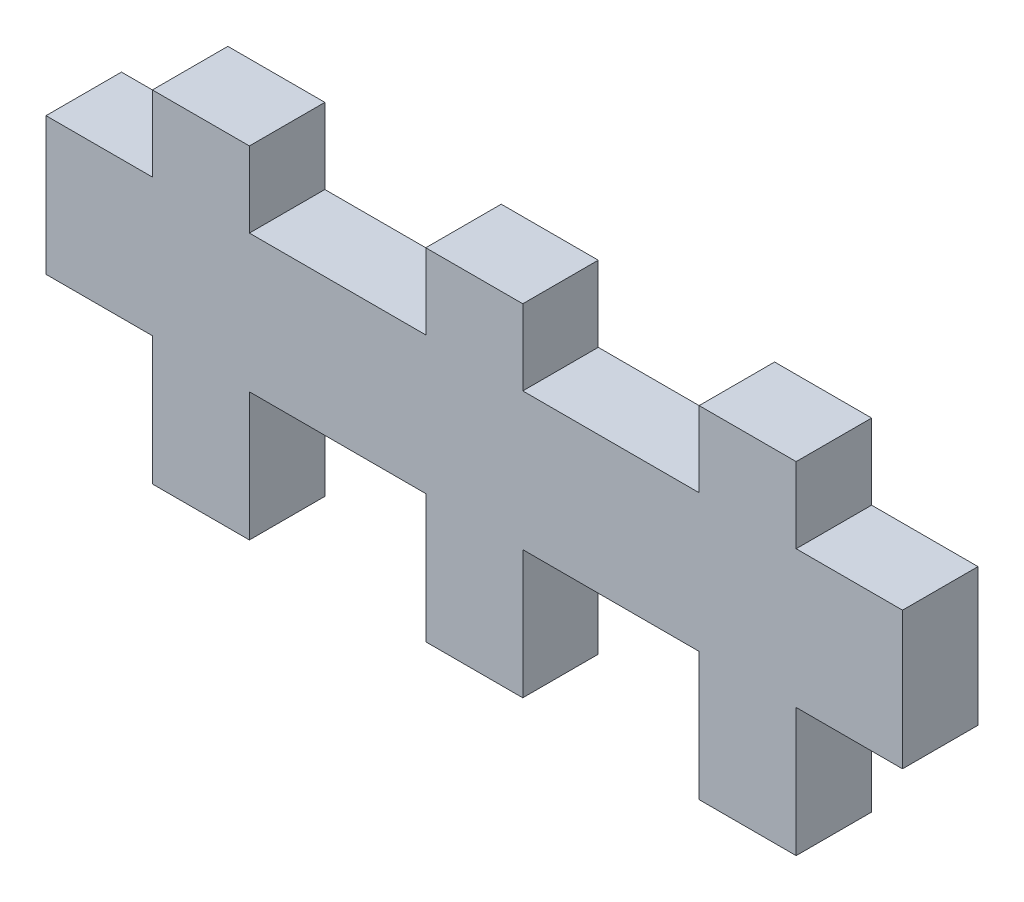
from build123d import *

# Parameters (mm, degrees)
SKETCH1_W           = 4
SKETCH1_H           = 3.175
SKETCH1_W_2         = 42.3
SKETCH1_H_2         = 5.7
SKETCH1_H_3         = 2.225
BOSS_EXTRUDE1_DEPTH = 3.175
CUT_EXTRUDE2_DEPTH  = 23.175
BOSS_EXTRUDE2_DEPTH = 3.175


with BuildPart() as part:
    # Sketch1 → Boss-Extrude1 (new body)
    with BuildSketch(Plane.XY):
        with Locations((-11.5, -1.5875)):
            Rectangle(SKETCH1_W, SKETCH1_H)
        with Locations((-11.5, 7.2875)):
            Rectangle(SKETCH1_W, SKETCH1_H)
        with Locations((0, 7.2875)):
            Rectangle(SKETCH1_W, SKETCH1_H)
        with Locations((0, -1.5875)):
            Rectangle(SKETCH1_W, SKETCH1_H)
        with Locations((11.5, 7.2875)):
            Rectangle(SKETCH1_W, SKETCH1_H)
        with Locations((11.5, -1.5875)):
            Rectangle(SKETCH1_W, SKETCH1_H)
        with Locations((0, 2.85)):
            Rectangle(SKETCH1_W_2, SKETCH1_H_2)
        with Locations((-11.5, -4.2875)):
            Rectangle(SKETCH1_W, SKETCH1_H_3)
        with Locations((0, -4.2875)):
            Rectangle(SKETCH1_W, SKETCH1_H_3)
        with Locations((11.5, -4.2875)):
            Rectangle(SKETCH1_W, SKETCH1_H_3)
    extrude(amount=BOSS_EXTRUDE1_DEPTH)

    # Sketch2 → Cut-Extrude2 (cut)
    with BuildSketch(Plane(origin=(0, 5.7, 0), x_dir=(1, 0, 0), z_dir=(0, 1, 0))):
        Polygon((-17.975, 0), (-21.15, 0), (-21.15, -3.175), align=None)
        Polygon((-17.975, -3.175), (-17.975, 0), (-21.15, -3.175), align=None)
        Polygon((21.15, -3.175), (17.975, -3.175), (17.975, 0), align=None)
        Polygon((21.15, -3.175), (17.975, 0), (21.15, 0), align=None)
    extrude(amount=-CUT_EXTRUDE2_DEPTH, mode=Mode.SUBTRACT)

    # Sketch3 → Boss-Extrude2 (add)
    with BuildSketch(Plane.XY.offset(3.175)):
        Polygon((-13.54064, -5.44064), (-9.45936, -5.44064), (-9.45936, -0.04064), (-2.04064, -0.04064), (-2.04064, -5.44064), (2.04064, -5.44064), (2.04064, -0.04064), (9.45936, -0.04064), (9.45936, -5.44064), (13.54064, -5.44064), (13.54064, -0.04064), (18.01564, -0.04064), (18.01564, 5.74064), (13.54064, 5.74064), (13.54064, 8.91564), (9.45936, 8.91564), (9.45936, 5.74064), (2.04064, 5.74064), (2.04064, 8.91564), (-2.04064, 8.91564), (-2.04064, 5.74064), (-9.45936, 5.74064), (-9.45936, 8.91564), (-13.54064, 8.91564), (-13.54064, 5.74064), (-18.01564, 5.74064), (-18.01564, -0.04064), (-13.54064, -0.04064), align=None)
    extrude(amount=-BOSS_EXTRUDE2_DEPTH)


solid = part.part
